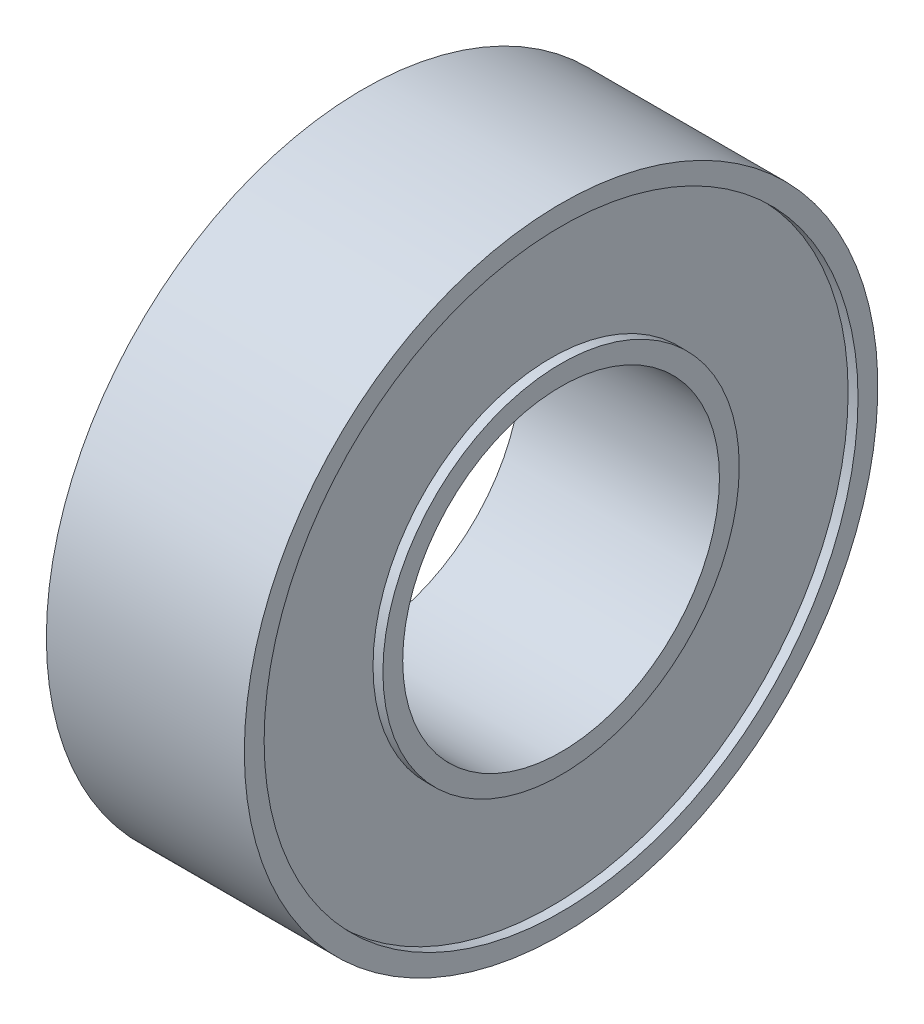
from build123d import *


with BuildPart() as part:
    # Sketch1 → Revolve1 (revolve)
    with BuildSketch(Plane.XY):
        Polygon((-2.5, 8), (2.5, 8), (2.5, 7.5), (2.25, 7.5), (2.25, 4.5), (2.5, 4.5), (2.5, 4), (-2.5, 4), (-2.5, 4.5), (-2.25, 4.5), (-2.25, 7.5), (-2.5, 7.5), align=None)
    revolve(axis=Axis((0, 0, 0), (1, 0, 0)))


solid = part.part
